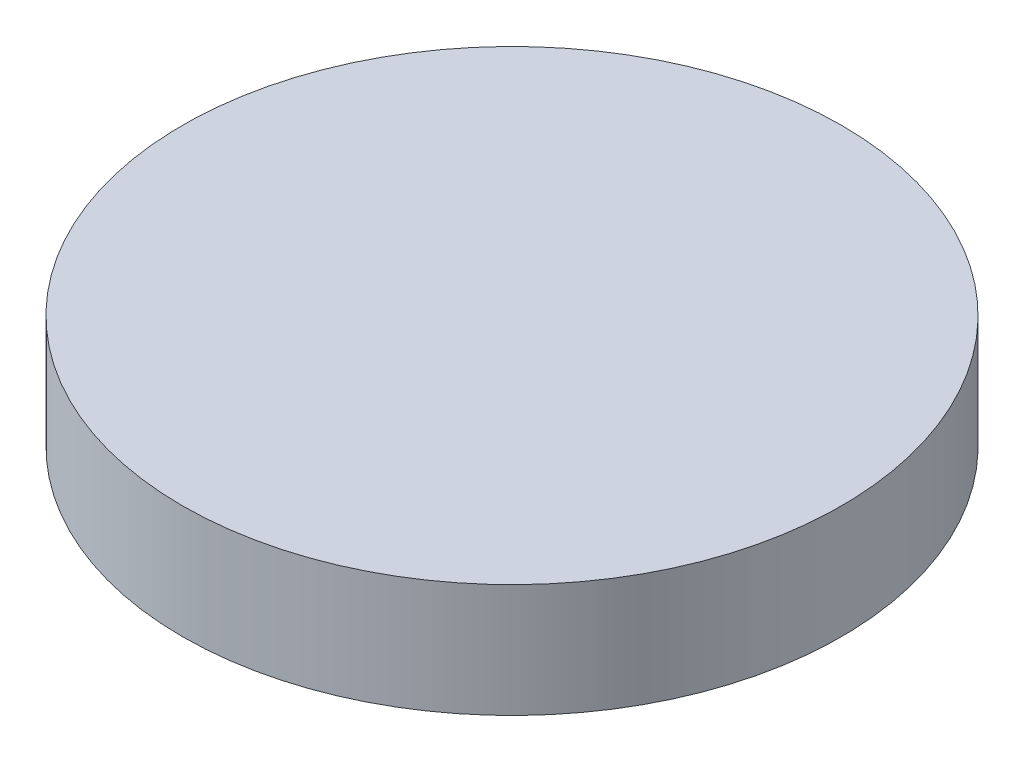
from build123d import *

# Parameters (mm, degrees)
SKETCH1_R        = 2.9075
EXTRUSION1_DEPTH = 1


with BuildPart() as part:
    # Sketch1 → Extrusion1 (new body)
    with BuildSketch(Plane(origin=(0, 0, 0), x_dir=(-1, 0, 0), z_dir=(0, 1, 0))):
        Circle(SKETCH1_R)
    extrude(amount=EXTRUSION1_DEPTH)


solid = part.part
